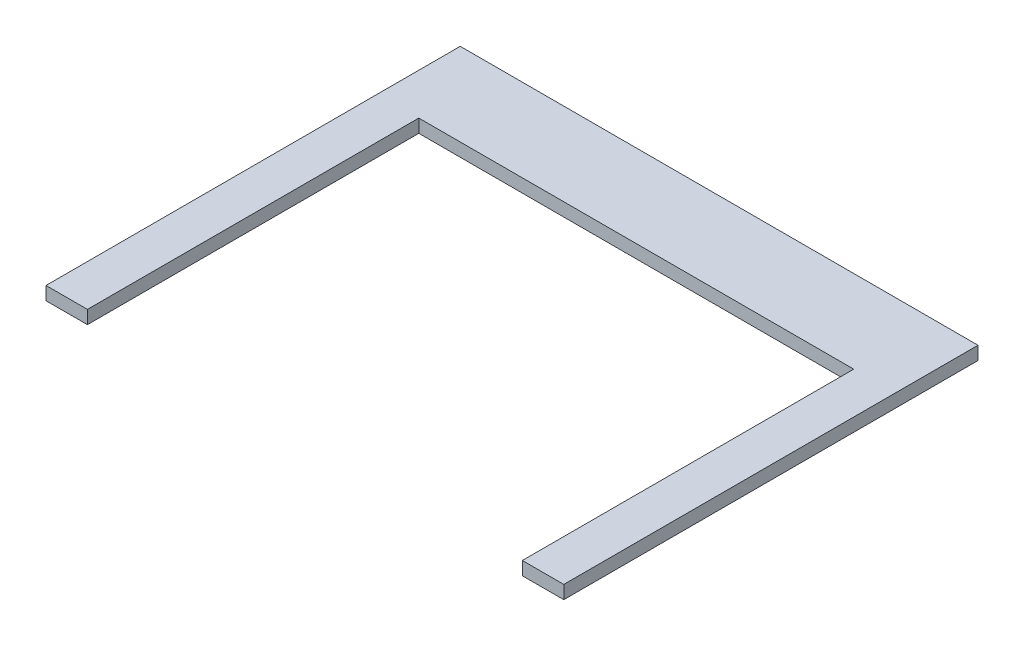
from build123d import *

# Parameters (mm, degrees)
BOSS_EXTRUDE1_DEPTH = 4.064


with BuildPart() as part:
    # Sketch1 → Boss-Extrude1 (new body)
    with BuildSketch(Plane(origin=(0, 0, 0), x_dir=(1, 0, 0), z_dir=(0, 1, 0))):
        Polygon((-79.375, 0), (-66.675, 0), (-66.675, 101.6), (66.675, 101.6), (66.675, 0), (79.375, 0), (79.375, 127), (-79.375, 127), align=None)
    extrude(amount=BOSS_EXTRUDE1_DEPTH)


solid = part.part
